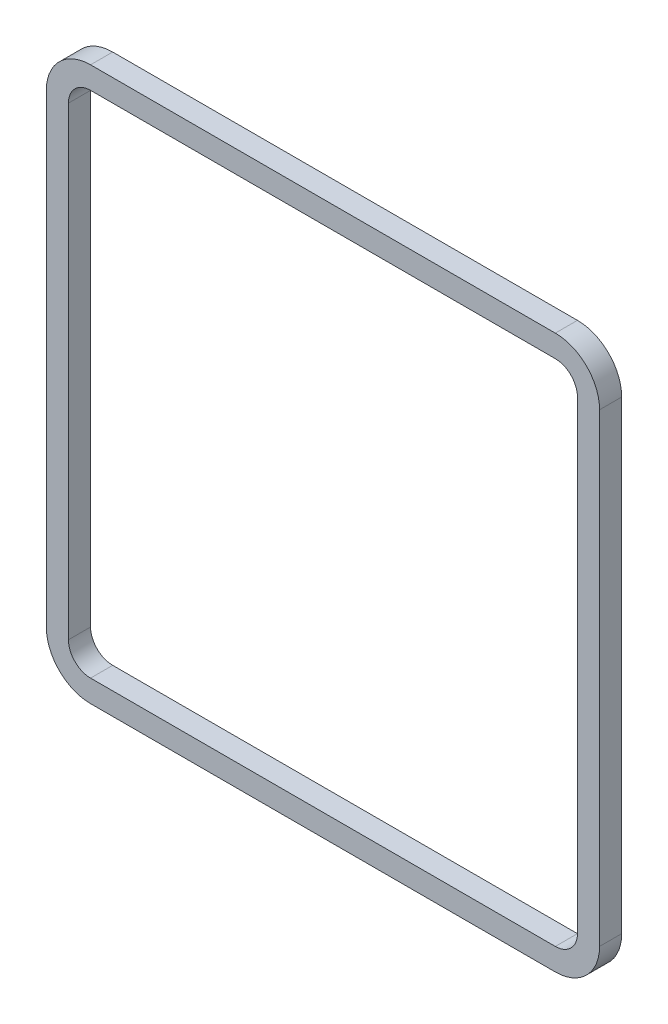
from build123d import *

# Parameters (mm, degrees)
BOSS_EXTRUDE1_DEPTH = 5.08


with BuildPart() as part:
    # Sketch1 → Boss-Extrude1 (new body)
    with BuildSketch(Plane.XY):
        with BuildLine():
            Line((53.34, 63.5), (-53.34, 63.5))
            ThreePointArc((-53.34, 63.5), (-60.524204897, 60.524204897), (-63.5, 53.34))
            Line((-63.5, 53.34), (-63.5, -53.34))
            ThreePointArc((-63.5, -53.34), (-60.524204897, -60.524204897), (-53.34, -63.5))
            Line((-53.34, -63.5), (53.34, -63.5))
            ThreePointArc((53.34, -63.5), (60.524204897, -60.524204897), (63.5, -53.34))
            Line((63.5, -53.34), (63.5, 53.34))
            ThreePointArc((63.5, 53.34), (60.524204897, 60.524204897), (53.34, 63.5))
        make_face()
        with BuildLine():
            Line((53.34, 58.42), (-53.34, 58.42))
            ThreePointArc((-53.34, 58.42), (-56.932102448, 56.932102448), (-58.42, 53.34))
            Line((-58.42, 53.34), (-58.42, -53.34))
            ThreePointArc((-58.42, -53.34), (-56.932102448, -56.932102448), (-53.34, -58.42))
            Line((-53.34, -58.42), (53.34, -58.42))
            ThreePointArc((53.34, -58.42), (56.932102448, -56.932102448), (58.42, -53.34))
            Line((58.42, -53.34), (58.42, 53.34))
            ThreePointArc((58.42, 53.34), (56.932102448, 56.932102448), (53.34, 58.42))
        make_face(mode=Mode.SUBTRACT)
    extrude(amount=BOSS_EXTRUDE1_DEPTH)


solid = part.part
